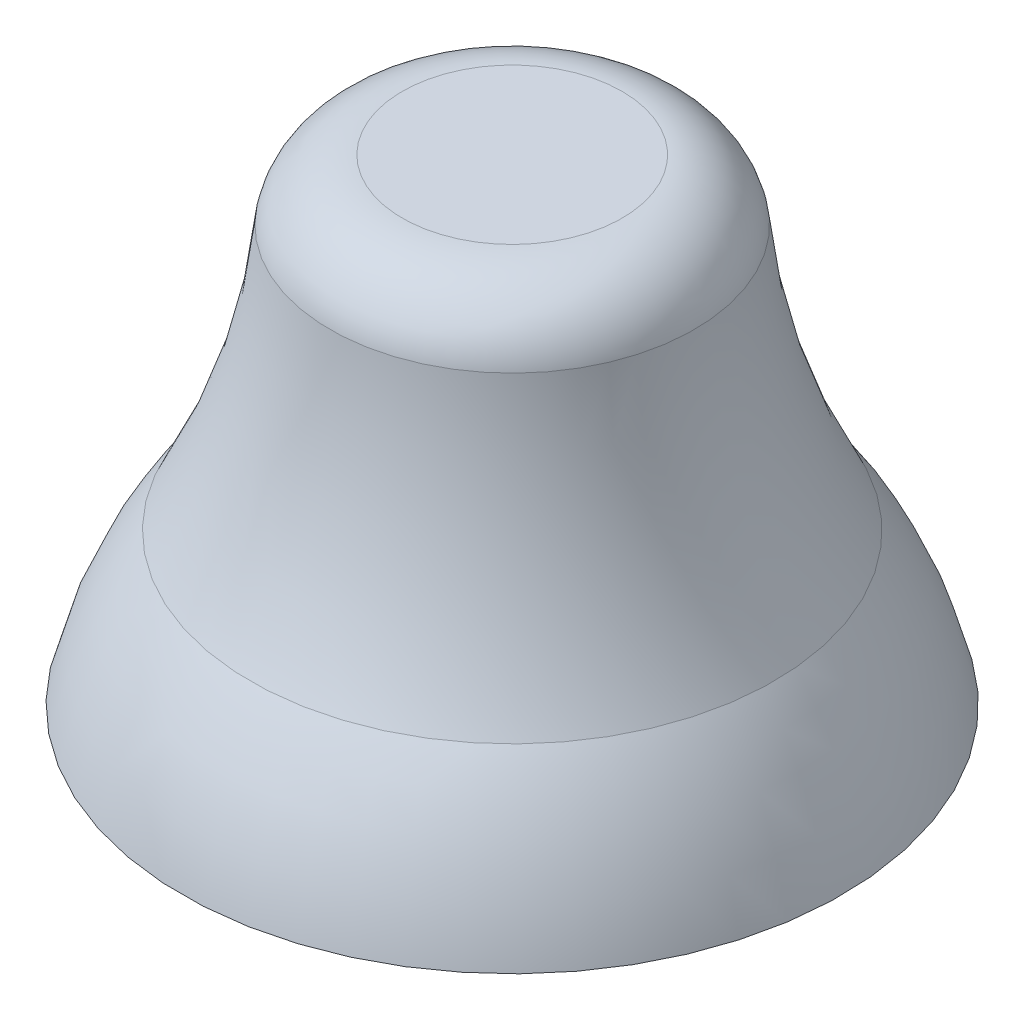
from build123d import *


with BuildPart() as part:
    # Sketch1 → Revolve1 (revolve)
    with BuildSketch(Plane.XY):
        with BuildLine():
            Line((0, 0), (0.9, 0))
            ThreePointArc((0.9, 0), (0.828391904, 0.21565751), (0.714, 0.412))
            ThreePointArc((0.714, 0.412), (0.569188592, 0.762610178), (0.496913687, 1.135))
            ThreePointArc((0.496913687, 1.135), (0.428452326, 1.253297097), (0.3, 1.3))
            Line((0.3, 1.3), (0, 1.3))
            Line((0, 1.3), (0, 0))
        make_face()
    revolve(axis=Axis((0, 0, 0), (0, 1, 0)))


solid = part.part
